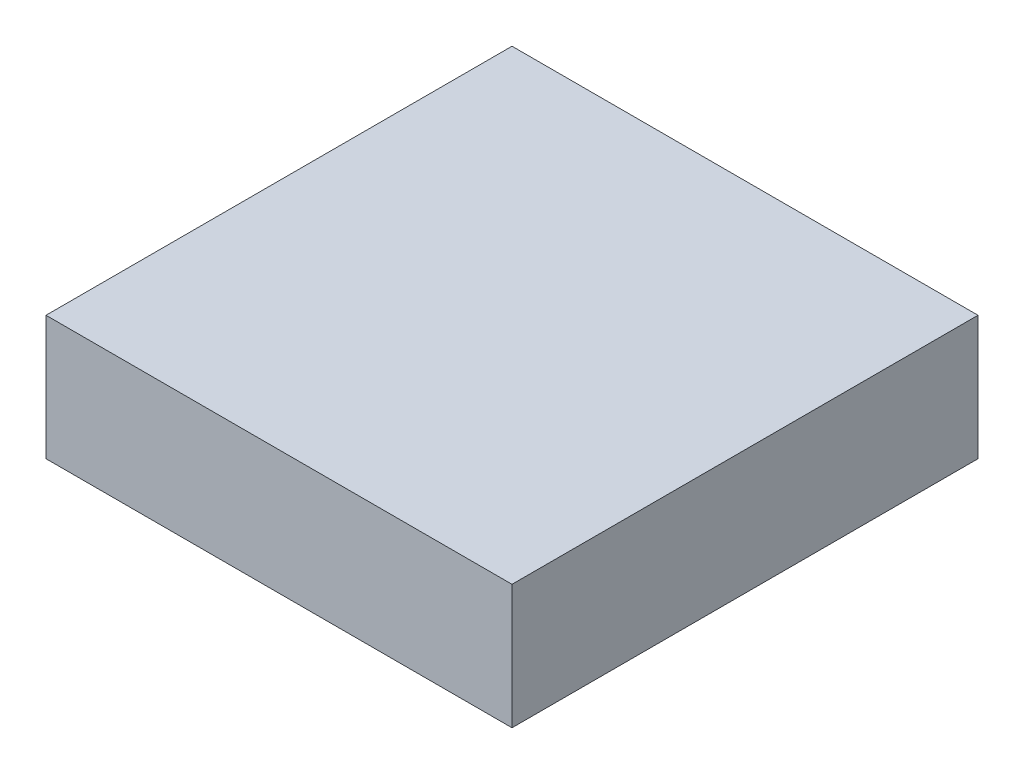
from build123d import *

# Parameters (mm, degrees)
SKETCH1_W           = 75
SKETCH1_H           = 75
BOSS_EXTRUDE1_DEPTH = 20


with BuildPart() as part:
    # Sketch1 → Boss-Extrude1 (new body)
    with BuildSketch(Plane(origin=(0, 0, 0), x_dir=(1, 0, 0), z_dir=(0, 1, 0))):
        with Locations((-64.711724527, 11.303270574)):
            Rectangle(SKETCH1_W, SKETCH1_H)
    extrude(amount=BOSS_EXTRUDE1_DEPTH)


solid = part.part
